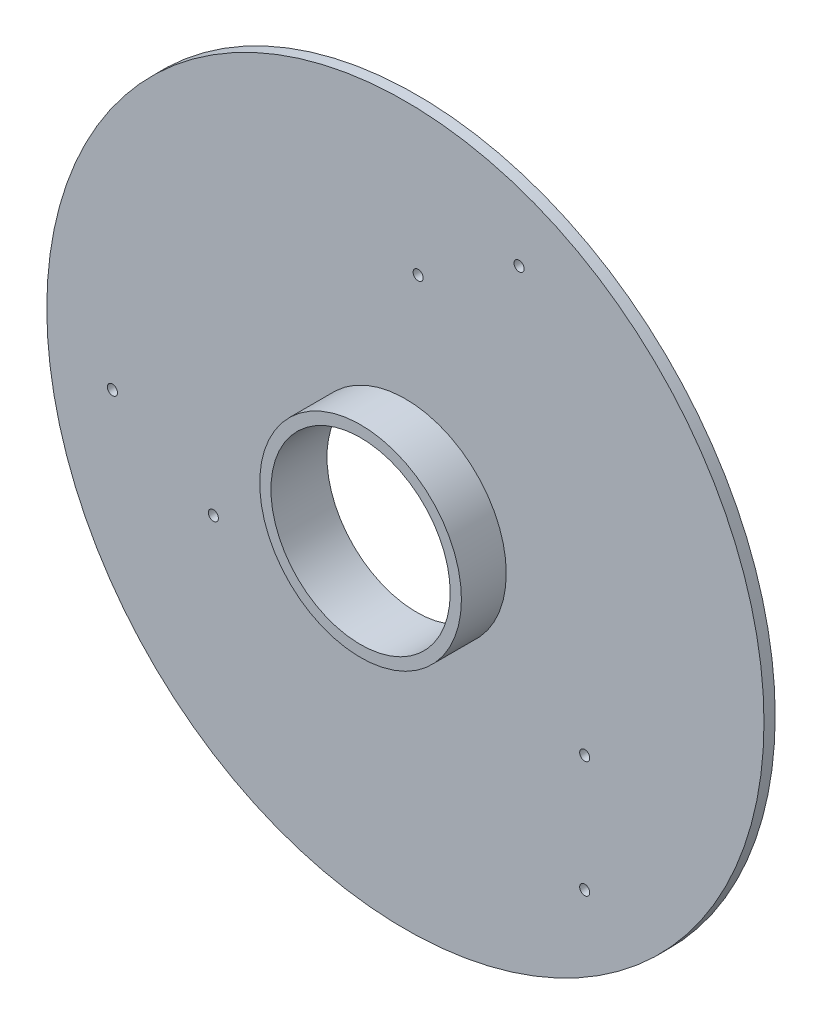
from build123d import *

# Parameters (mm, degrees)
SKETCH2_R           = 1600
SKETCH2_R_2         = 22.5
BOSS_EXTRUDE1_DEPTH = 50
SKETCH3_R           = 400
CUT_EXTRUDE1_DEPTH  = 51
SKETCH4_R           = 450
BOSS_EXTRUDE2_DEPTH = 200
SKETCH5_R           = 400
CUT_EXTRUDE2_DEPTH  = 251


with BuildPart() as part:
    # Sketch2 → Boss-Extrude1 (new body)
    with BuildSketch(Plane.XY):
        Circle(SKETCH2_R)
        with Locations((800, -527.5)):
            Circle(SKETCH2_R_2, mode=Mode.SUBTRACT)
        with Locations((800, -1047.5)):
            Circle(SKETCH2_R_2, mode=Mode.SUBTRACT)
        with Locations((-856.828400496, -429.070323028)):
            Circle(SKETCH2_R_2, mode=Mode.SUBTRACT)
        with Locations((-1307.161610464, -169.070323028)):
            Circle(SKETCH2_R_2, mode=Mode.SUBTRACT)
        with Locations((56.828400496, 956.570323028)):
            Circle(SKETCH2_R_2, mode=Mode.SUBTRACT)
        with Locations((507.161610464, 1216.570323028)):
            Circle(SKETCH2_R_2, mode=Mode.SUBTRACT)
    extrude(amount=BOSS_EXTRUDE1_DEPTH)

    # Sketch3 → Cut-Extrude1 (cut, through all)
    with BuildSketch(Plane.XY.offset(50)):
        Circle(SKETCH3_R)
    extrude(amount=-CUT_EXTRUDE1_DEPTH, mode=Mode.SUBTRACT)

    # Sketch4 → Boss-Extrude2 (add)
    with BuildSketch(Plane.XY.offset(50)):
        Circle(SKETCH4_R)
    extrude(amount=BOSS_EXTRUDE2_DEPTH)

    # Sketch5 → Cut-Extrude2 (cut, through all)
    with BuildSketch(Plane.XY.offset(250)):
        Circle(SKETCH5_R)
    extrude(amount=-CUT_EXTRUDE2_DEPTH, mode=Mode.SUBTRACT)


solid = part.part
